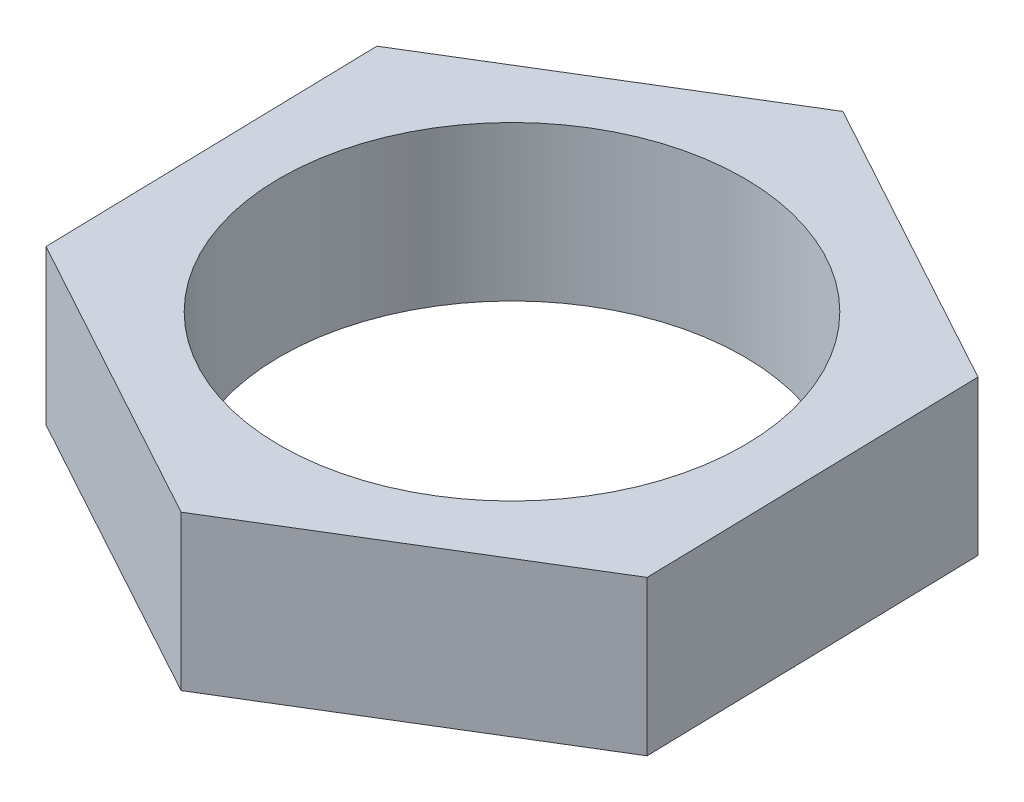
from build123d import *

# Parameters (mm, degrees)
BOSS_EXTRUDE1_DEPTH = 5
SKETCH3_R           = 7.5
CUT_EXTRUDE1_DEPTH  = 5


with BuildPart() as part:
    # Sketch1 → Boss-Extrude1 (new body)
    with BuildSketch(Plane(origin=(0, 0, 0), x_dir=(1, 0, 0), z_dir=(0, 1, 0))):
        Polygon((9.62809621, -5.256719195), (9.366500469, 5.709816311), (-0.261595741, 10.966535506), (-9.62809621, 5.256719195), (-9.366500469, -5.709816311), (0.261595741, -10.966535506), align=None)
    extrude(amount=BOSS_EXTRUDE1_DEPTH)

    # Sketch3 → Cut-Extrude1 (cut)
    with BuildSketch(Plane(origin=(0, 5, 0), x_dir=(1, 0, 0), z_dir=(0, 1, 0))):
        Circle(SKETCH3_R)
    extrude(amount=-CUT_EXTRUDE1_DEPTH, mode=Mode.SUBTRACT)


solid = part.part
